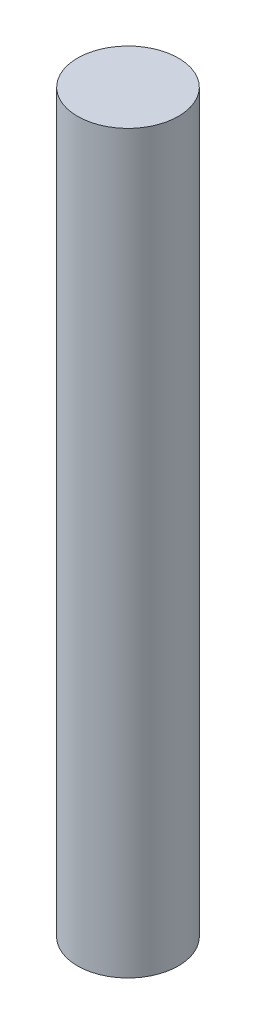
from build123d import *

# Parameters (mm, degrees)
SKIZZE1_R                       = 2.4
AUFSATZ_LINEAR_AUSTRAGEN1_DEPTH = 35


with BuildPart() as part:
    # Skizze1 → Aufsatz-Linear austragen1 (new body)
    with BuildSketch(Plane(origin=(0, 0, 0), x_dir=(1, 0, 0), z_dir=(0, 1, 0))):
        Circle(SKIZZE1_R)
    extrude(amount=AUFSATZ_LINEAR_AUSTRAGEN1_DEPTH)


solid = part.part
